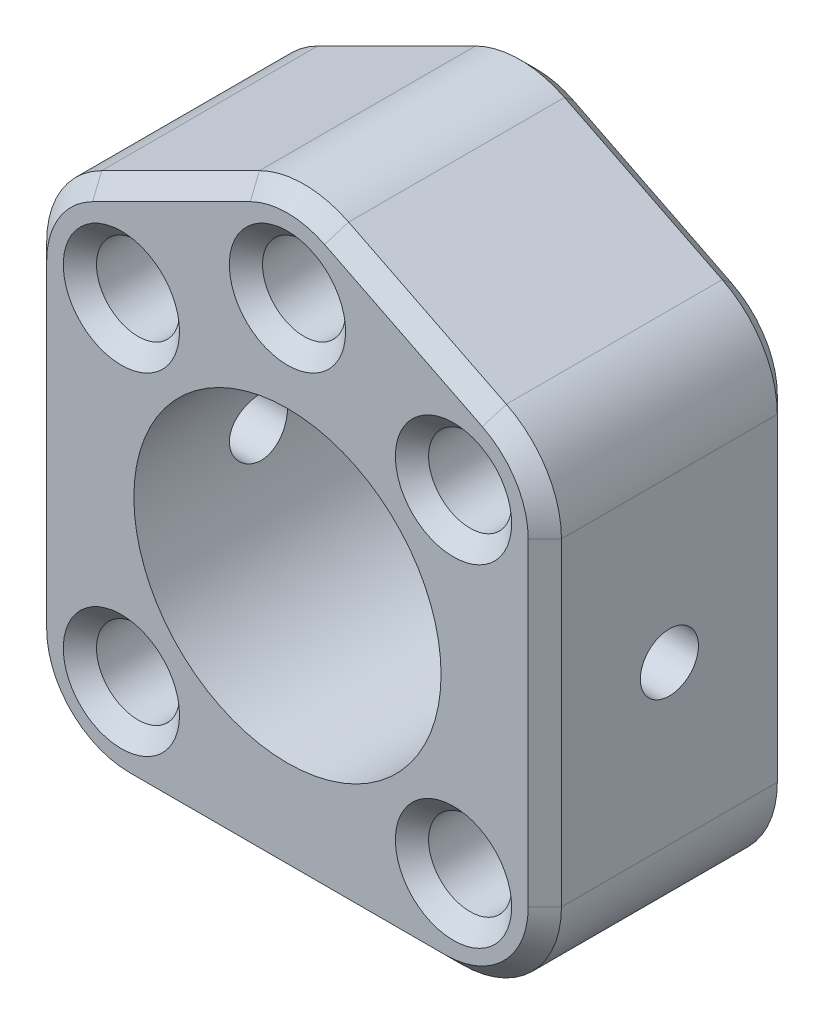
from build123d import *

# Parameters (mm, degrees)
SKETCH_1_R               = 9.25
SKETCH_1_R_2             = 2.5
EXTRUDE_1_DEPTH          = 7.5
SKETCH_3_R               = 1.75
CUT_EXTRUDE_1_DEPTH      = 16.5
CUT_EXTRUDE_1_DEPTH_BACK = 16.5
CHAMFER_1_SIZE           = 1
CHAMFER_2_SIZE           = 1


with BuildPart() as part:
    # ｽｹｯﾁ1 → ﾎﾞｽ - 押し出し1 (new body, symmetric)
    with BuildSketch(Plane.XY):
        with BuildLine():
            Line((2.683281573, 19.807546152), (12.183281573, 15.057546152))
            ThreePointArc((12.183281573, 15.057546152), (14.60390485, 12.845369678), (15.5, 9.690983006))
            Line((15.5, 9.690983006), (15.5, -9.5))
            ThreePointArc((15.5, -9.5), (13.742640687, -13.742640687), (9.5, -15.5))
            Line((9.5, -15.5), (-9.5, -15.5))
            ThreePointArc((-9.5, -15.5), (-13.742640687, -13.742640687), (-15.5, -9.5))
            Line((-15.5, -9.5), (-15.5, 9.690983006))
            ThreePointArc((-15.5, 9.690983006), (-14.60390485, 12.845369678), (-12.183281573, 15.057546152))
            Line((-12.183281573, 15.057546152), (-2.683281573, 19.807546152))
            ThreePointArc((-2.683281573, 19.807546152), (0, 20.440983006), (2.683281573, 19.807546152))
        make_face()
        Circle(SKETCH_1_R, mode=Mode.SUBTRACT)
        with Locations((-10, -10)):
            Circle(SKETCH_1_R_2, mode=Mode.SUBTRACT)
        with Locations((-10, 10)):
            Circle(SKETCH_1_R_2, mode=Mode.SUBTRACT)
        with Locations((10, 10)):
            Circle(SKETCH_1_R_2, mode=Mode.SUBTRACT)
        with Locations((10, -10)):
            Circle(SKETCH_1_R_2, mode=Mode.SUBTRACT)
        with Locations((0, 15)):
            Circle(SKETCH_1_R_2, mode=Mode.SUBTRACT)
    extrude(amount=EXTRUDE_1_DEPTH, both=True)

    # ｽｹｯﾁ3 → ｶｯﾄ - 押し出し1 (cut, two sides)
    with BuildSketch(Plane(origin=(0, 0, 0), x_dir=(0, 0, -1), z_dir=(1, 0, 0))) as cut_extrude_1_sk:
        Circle(SKETCH_3_R)
    extrude(amount=CUT_EXTRUDE_1_DEPTH, mode=Mode.SUBTRACT)
    extrude(cut_extrude_1_sk.sketch, amount=-CUT_EXTRUDE_1_DEPTH_BACK, mode=Mode.SUBTRACT)

    # 面取り1
    chamfer_1_edges = [part.edges().sort_by_distance(p)[0] for p in [
        (-12.5, -10, -7.5),
        (-12.5, -10, 7.5),
        (-12.5, 10, -7.5),
        (-12.5, 10, 7.5),
        (7.5, 10, -7.5),
        (7.5, 10, 7.5),
        (7.5, -10, -7.5),
        (7.5, -10, 7.5),
        (-2.5, 15, -7.5),
        (-2.5, 15, 7.5),
    ]]
    chamfer(chamfer_1_edges, length=CHAMFER_1_SIZE)

    # 面取り2
    chamfer_2_edges = [part.edges().sort_by_distance(p)[0] for p in [
        (-15.5, 0.095491503, -7.5),
        (-14.60390485, 12.845369678, -7.5),
        (-7.433281573, 17.432546152, -7.5),
        (0, 20.440983006, -7.5),
        (7.433281573, 17.432546152, -7.5),
        (14.60390485, 12.845369678, -7.5),
        (15.5, 0.095491503, -7.5),
        (13.742640687, -13.742640687, 7.5),
        (13.742640687, -13.742640687, -7.5),
        (0, -15.5, -7.5),
        (-13.742640687, -13.742640687, -7.5),
        (15.5, 0.095491503, 7.5),
        (14.60390485, 12.845369678, 7.5),
        (7.433281573, 17.432546152, 7.5),
        (0, 20.440983006, 7.5),
        (-7.433281573, 17.432546152, 7.5),
        (-14.60390485, 12.845369678, 7.5),
        (-15.5, 0.095491503, 7.5),
        (-13.742640687, -13.742640687, 7.5),
        (0, -15.5, 7.5),
    ]]
    chamfer(chamfer_2_edges, length=CHAMFER_2_SIZE)


solid = part.part
